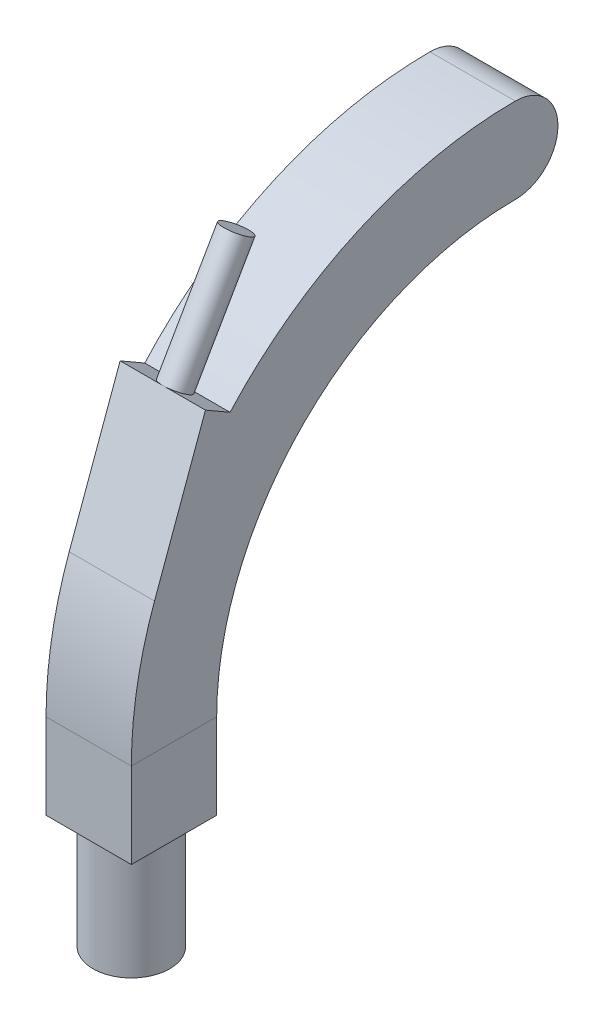
from build123d import *

# Parameters (mm, degrees)
SKETCH2_W           = 30
SKETCH2_H           = 30
SKETCH3_R           = 13.5
BOSS_EXTRUDE1_DEPTH = 40
BOSS_EXTRUDE2_DEPTH = 30
BOSS_EXTRUDE3_START = -15
BOSS_EXTRUDE3_DEPTH = 30
SKETCH6_R           = 5
BOSS_EXTRUDE4_DEPTH = 43.044915


with BuildPart() as part:
    # Sweep1: sweep along a path in Sketch1
    with BuildLine(Plane(origin=(0, 0, 0), x_dir=(0, 0, -1), z_dir=(1, 0, 0))) as sweep1_path:
        Line((0, 0), (0, 30))
        ThreePointArc((0, 30), (35.147186258, 114.852813742), (120, 150))
    # Sketch2 → Sweep1 (sweep)
    with BuildSketch(Plane(origin=(0, 0, 0), x_dir=(1, 0, 0), z_dir=(0, 1, 0))):
        Rectangle(SKETCH2_W, SKETCH2_H)
    sweep(path=sweep1_path.line)

    # Sketch3 → Boss-Extrude1 (add)
    with BuildSketch(Plane.XZ):
        Circle(SKETCH3_R)
    extrude(amount=BOSS_EXTRUDE1_DEPTH)

    # Sketch4 → Boss-Extrude2 (add)
    with BuildSketch(Plane(origin=(15, 0, 0), x_dir=(0, 0, -1), z_dir=(1, 0, 0))):
        with BuildLine():
            Line((120, 165), (120, 135))
            ThreePointArc((120, 135), (135, 150), (120, 165))
        make_face()
    extrude(amount=-BOSS_EXTRUDE2_DEPTH)

    # Sketch5 → Boss-Extrude3 (add)
    with BuildSketch(Plane(origin=(0, 0, 0), x_dir=(0, 0, -1), z_dir=(1, 0, 0)).offset(BOSS_EXTRUDE3_START)):
        with BuildLine():
            Line((19.707410468, 120.368116529), (11.04715643, 125.368116529))
            Line((11.04715643, 125.368116529), (-6.858503806, 76.172719349))
            ThreePointArc((-6.858503806, 76.172719349), (4.294714537, 99.550606869), (19.707410468, 120.368116529))
        make_face()
    extrude(amount=BOSS_EXTRUDE3_DEPTH)

    # Sketch6 → Boss-Extrude4 (add)
    with BuildSketch(Plane(origin=(0, 98.809646451, -57.047775977), x_dir=(1, 0, 0), z_dir=(0, 0.866025404, -0.5))):
        with Locations((0, -48.116940156)):
            Circle(SKETCH6_R)
    extrude(amount=BOSS_EXTRUDE4_DEPTH)


solid = part.part
